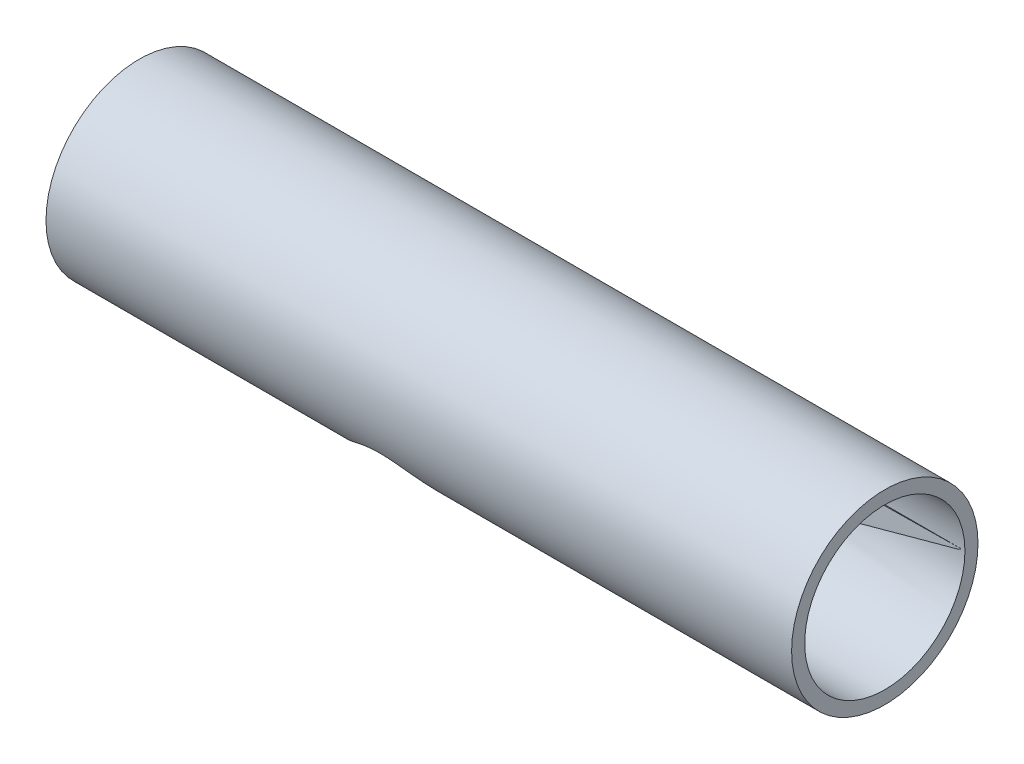
from build123d import *

# Parameters (mm, degrees)
SKETCH1_R           = 25
BOSS_EXTRUDE3_DEPTH = 200
SKETCH3_R           = 21.5
CUT_EXTRUDE1_DEPTH  = 190
CUT_EXTRUDE2_REACH  = 202
SKETCH5_R           = 10
CUT_EXTRUDE3_REACH  = 27
SKETCH6_R           = 21.5


with BuildPart() as part:
    # Sketch1 → Boss-Extrude3 (new body)
    with BuildSketch(Plane(origin=(0, 0, 0), x_dir=(0, 0, -1), z_dir=(1, 0, 0))):
        Circle(SKETCH1_R)
    extrude(amount=BOSS_EXTRUDE3_DEPTH)

    # Sketch3 → Cut-Extrude1 (cut)
    with BuildSketch(Plane(origin=(200, 0, 0), x_dir=(0, 0, -1), z_dir=(1, 0, 0))):
        Circle(SKETCH3_R)
    extrude(amount=-CUT_EXTRUDE1_DEPTH, mode=Mode.SUBTRACT)

    # Sketch5 → Cut-Extrude2 (cut, up to next)
    with BuildSketch(Plane.ZY, mode=Mode.PRIVATE) as cut_extrude2_sk1:
        Circle(SKETCH5_R)
    cut_extrude2_tool1 = extrude(cut_extrude2_sk1.sketch, amount=-CUT_EXTRUDE2_REACH, mode=Mode.PRIVATE) & part.part
    add(cut_extrude2_tool1.solids().sort_by_distance((0, 0, 0))[0], mode=Mode.SUBTRACT)

    # Sketch6 → Cut-Extrude3 (cut, up to next)
    with BuildSketch(Plane(origin=(0, 0, 0), x_dir=(1, 0, 0), z_dir=(0, 1, 0)), mode=Mode.PRIVATE) as cut_extrude3_sk1:
        with Locations((86, 0)):
            Circle(SKETCH6_R)
    cut_extrude3_tool1 = extrude(cut_extrude3_sk1.sketch, amount=-CUT_EXTRUDE3_REACH, mode=Mode.PRIVATE) & part.part
    add(cut_extrude3_tool1.solids().sort_by_distance((86, 0, 0))[0], mode=Mode.SUBTRACT)


solid = part.part
